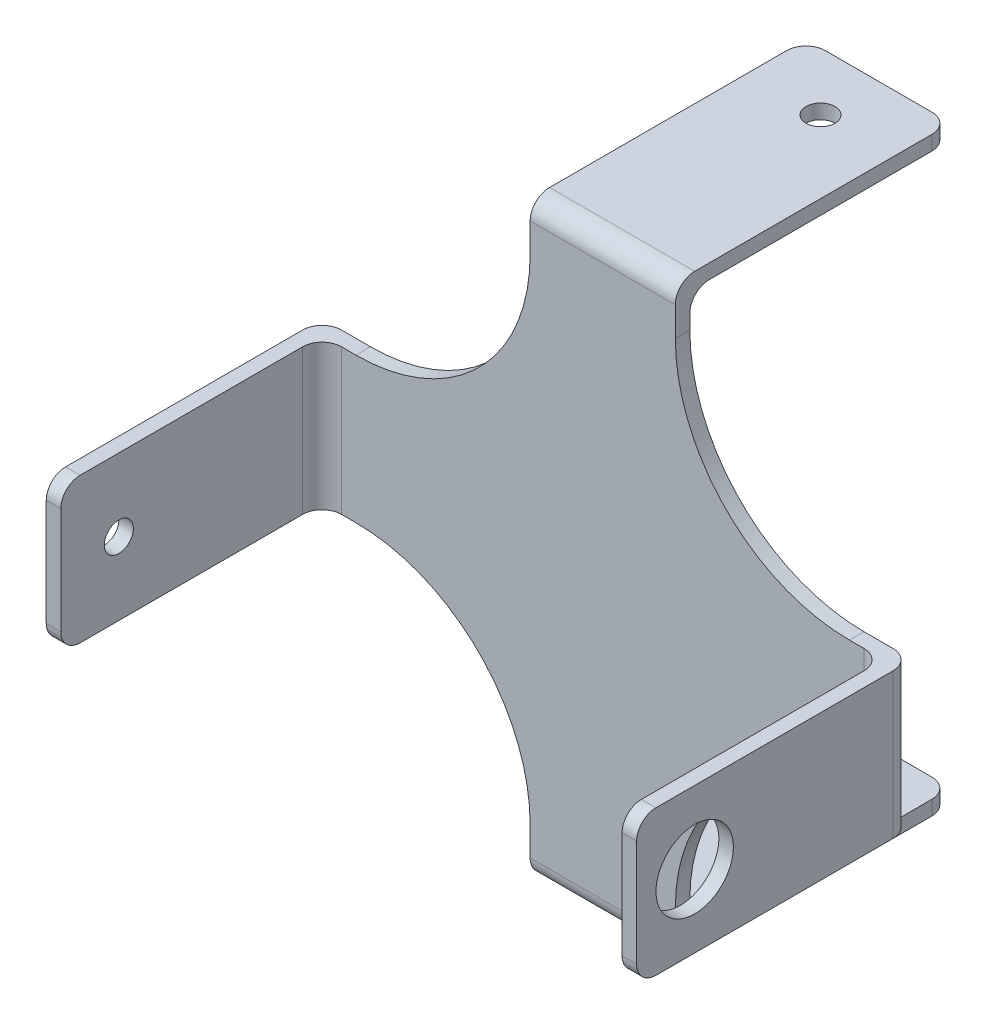
from build123d import *

# Parameters (mm, degrees)
SKETCH1_W           = 15
SKETCH1_H           = 21.5
SKETCH1_W_2         = 21.5
SKETCH1_H_2         = 15
BOSS_EXTRUDE1_DEPTH = 1.5
BOSS_EXTRUDE2_START = -1.5
SKETCH2_W           = 1.5
SKETCH2_H           = 15
BOSS_EXTRUDE2_DEPTH = 28.5
BOSS_EXTRUDE3_START = -1.5
SKETCH3_W           = 15
SKETCH3_H           = 1.5
BOSS_EXTRUDE3_DEPTH = 28.5
SKETCH4_R           = 1.5
CUT_EXTRUDE1_DEPTH  = 62
SKETCH5_R           = 1.5
CUT_EXTRUDE2_DEPTH  = 62
FILLET1_R           = 2
FILLET2_R           = 2
FILLET3_R           = 18
CUT_EXTRUDE3_REACH  = 63
SKETCH6_R           = 4
CUT_EXTRUDE4_REACH  = 63
SKETCH7_R           = 4


with BuildPart() as part:
    # Sketch1 → Boss-Extrude1 (new body)
    with BuildSketch(Plane.XY):
        with Locations((0, 18.25)):
            Rectangle(SKETCH1_W, SKETCH1_H)
        with Locations((-18.25, 0)):
            Rectangle(SKETCH1_W_2, SKETCH1_H_2)
        Rectangle(SKETCH1_W, SKETCH1_H_2)
        with Locations((18.25, 0)):
            Rectangle(SKETCH1_W_2, SKETCH1_H_2)
        with Locations((0, -18.25)):
            Rectangle(SKETCH1_W, SKETCH1_H)
    extrude(amount=BOSS_EXTRUDE1_DEPTH)

    # Sketch2 → Boss-Extrude2 (add)
    with BuildSketch(Plane.XY.offset(1.5).offset(BOSS_EXTRUDE2_START)):
        with Locations((-29.75, 0)):
            Rectangle(SKETCH2_W, SKETCH2_H)
        with Locations((29.75, 0)):
            Rectangle(SKETCH2_W, SKETCH2_H)
    extrude(amount=BOSS_EXTRUDE2_DEPTH)

    # Sketch3 → Boss-Extrude3 (add)
    with BuildSketch(Plane(origin=(0, 0, 0), x_dir=(-1, 0, 0), z_dir=(0, 0, -1)).offset(BOSS_EXTRUDE3_START)):
        with Locations((0, 29.75)):
            Rectangle(SKETCH3_W, SKETCH3_H)
        with Locations((0, -29.75)):
            Rectangle(SKETCH3_W, SKETCH3_H)
    extrude(amount=BOSS_EXTRUDE3_DEPTH)

    # Sketch4 → Cut-Extrude1 (cut, through all)
    with BuildSketch(Plane(origin=(30.5, 0, 0), x_dir=(0, 0, -1), z_dir=(1, 0, 0))):
        with Locations((-22.5, 0)):
            Circle(SKETCH4_R)
    extrude(amount=-CUT_EXTRUDE1_DEPTH, mode=Mode.SUBTRACT)

    # Sketch5 → Cut-Extrude2 (cut, through all)
    with BuildSketch(Plane(origin=(0, 30.5, 0), x_dir=(1, 0, 0), z_dir=(0, 1, 0))):
        with Locations((0, 21)):
            Circle(SKETCH5_R)
    extrude(amount=-CUT_EXTRUDE2_DEPTH, mode=Mode.SUBTRACT)

    # Fillet1
    fillet1_edges = [part.edges().sort_by_distance(p)[0] for p in [
        (-7.5, -29.75, -27),
        (7.5, -29.75, -27),
        (-7.5, 29.75, -27),
        (7.5, 29.75, -27),
        (-29.75, 7.5, 28.5),
        (-29.75, -7.5, 28.5),
        (29.75, -7.5, 28.5),
        (29.75, 7.5, 28.5),
    ]]
    fillet(fillet1_edges, radius=FILLET1_R)

    # Fillet2
    fillet2_edges = [part.edges().sort_by_distance(p)[0] for p in [
        (29, 0, 1.5),
        (30.5, 0, 0),
        (-30.5, 0, 0),
        (-29, 0, 1.5),
        (0, 29, 0),
        (0, -29, 0),
        (0, -30.5, 1.5),
        (0, 30.5, 1.5),
    ]]
    fillet(fillet2_edges, radius=FILLET2_R)

    # Fillet3
    fillet3_edges = [part.edges().sort_by_distance(p)[0] for p in [
        (-7.5, 7.5, 0.75),
        (-7.5, -7.5, 0.75),
        (7.5, -7.5, 0.75),
        (7.5, 7.5, 0.75),
    ]]
    fillet(fillet3_edges, radius=FILLET3_R)

    # Sketch6 → Cut-Extrude3 (cut, up to next)
    with BuildSketch(Plane(origin=(30.5, 0, 0), x_dir=(0, 0, -1), z_dir=(1, 0, 0)), mode=Mode.PRIVATE) as cut_extrude3_sk1:
        with Locations((-22.5, 0)):
            Circle(SKETCH6_R)
    cut_extrude3_tool1 = extrude(cut_extrude3_sk1.sketch, amount=-CUT_EXTRUDE3_REACH, mode=Mode.PRIVATE) & part.part
    add(cut_extrude3_tool1.solids().sort_by_distance((30.5, 0, 22.5))[0], mode=Mode.SUBTRACT)

    # Sketch7 → Cut-Extrude4 (cut, up to next)
    with BuildSketch(Plane.XZ.offset(30.5), mode=Mode.PRIVATE) as cut_extrude4_sk1:
        with Locations((0, -21)):
            Circle(SKETCH7_R)
    cut_extrude4_tool1 = extrude(cut_extrude4_sk1.sketch, amount=-CUT_EXTRUDE4_REACH, mode=Mode.PRIVATE) & part.part
    add(cut_extrude4_tool1.solids().sort_by_distance((0, -30.5, -21))[0], mode=Mode.SUBTRACT)


solid = part.part
